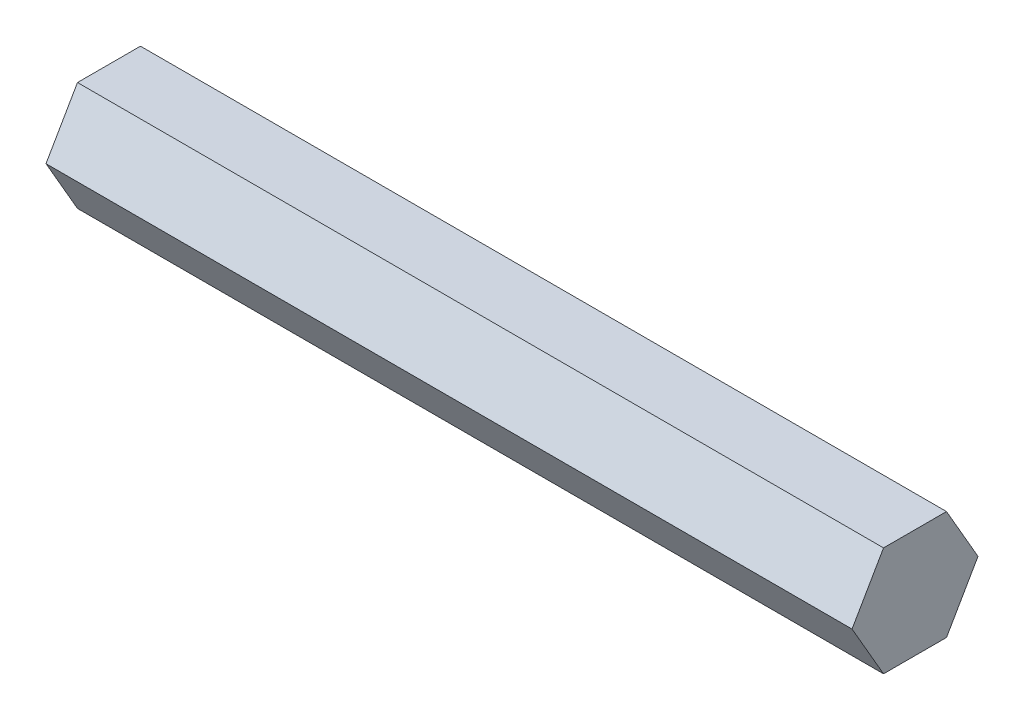
from build123d import *

# Parameters (mm, degrees)
BOSS_EXTRUDE1_DEPTH = 93.85


with BuildPart() as part:
    # Sketch1 → Boss-Extrude1 (new body)
    with BuildSketch(Plane(origin=(0, 0, 0), x_dir=(0, 0, -1), z_dir=(1, 0, 0))):
        Polygon((7.332348419, 0), (3.666174209, 6.35), (-3.666174209, 6.35), (-7.332348419, 0), (-3.666174209, -6.35), (3.666174209, -6.35), align=None)
    extrude(amount=BOSS_EXTRUDE1_DEPTH)


solid = part.part
